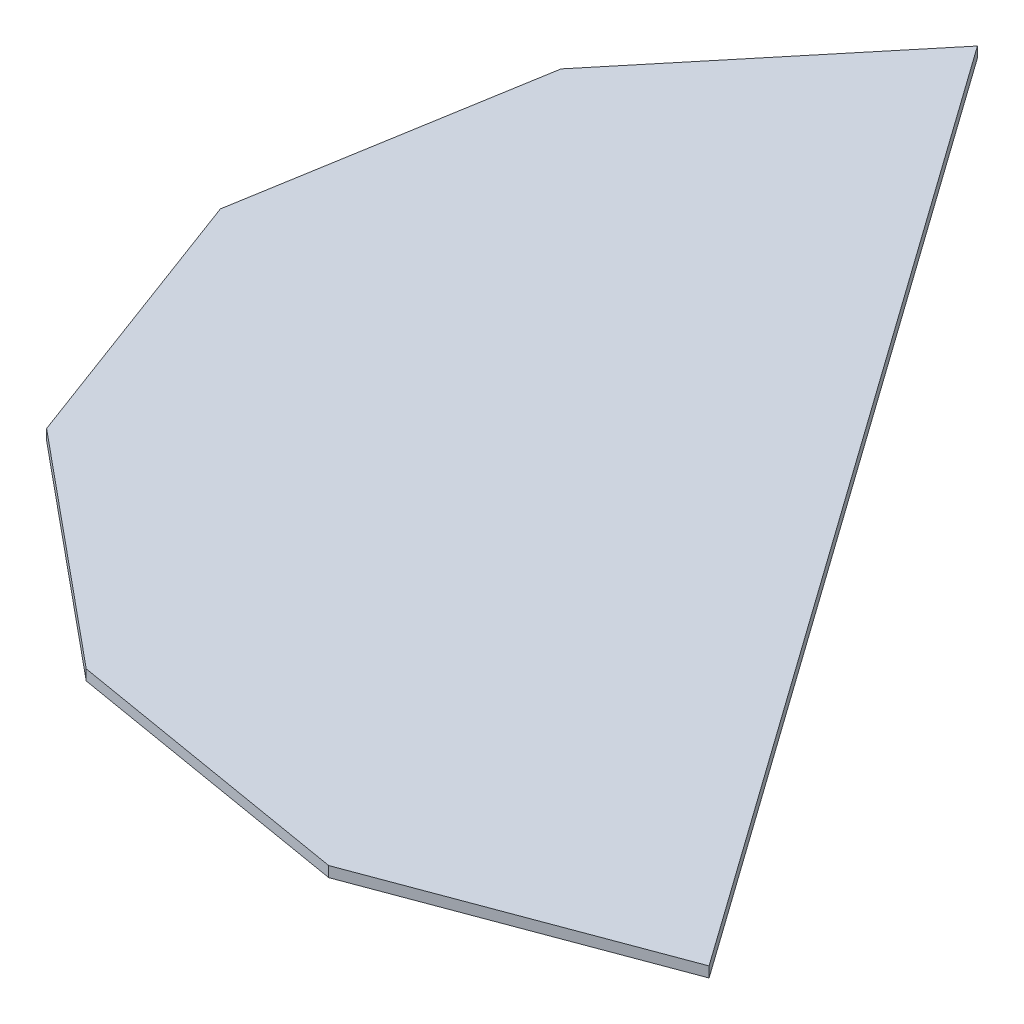
from build123d import *

# Parameters (mm, degrees)
BOSS_EXTRUDE1_DEPTH = 2.794


with BuildPart() as part:
    # Sketch1 → Boss-Extrude1 (new body)
    with BuildSketch(Plane(origin=(0, 0, 0), x_dir=(1, 0, 0), z_dir=(0, 1, 0))):
        Polygon((-151.713510023, -14.448905717), (-124.163300919, -88.369874419), (-63.343635604, -138.612206636), (14.448905717, -151.713510023), (88.369874419, -124.163300919), (-88.369874419, 124.163300919), (-138.612206636, 63.343635604), align=None)
    extrude(amount=BOSS_EXTRUDE1_DEPTH)


solid = part.part
